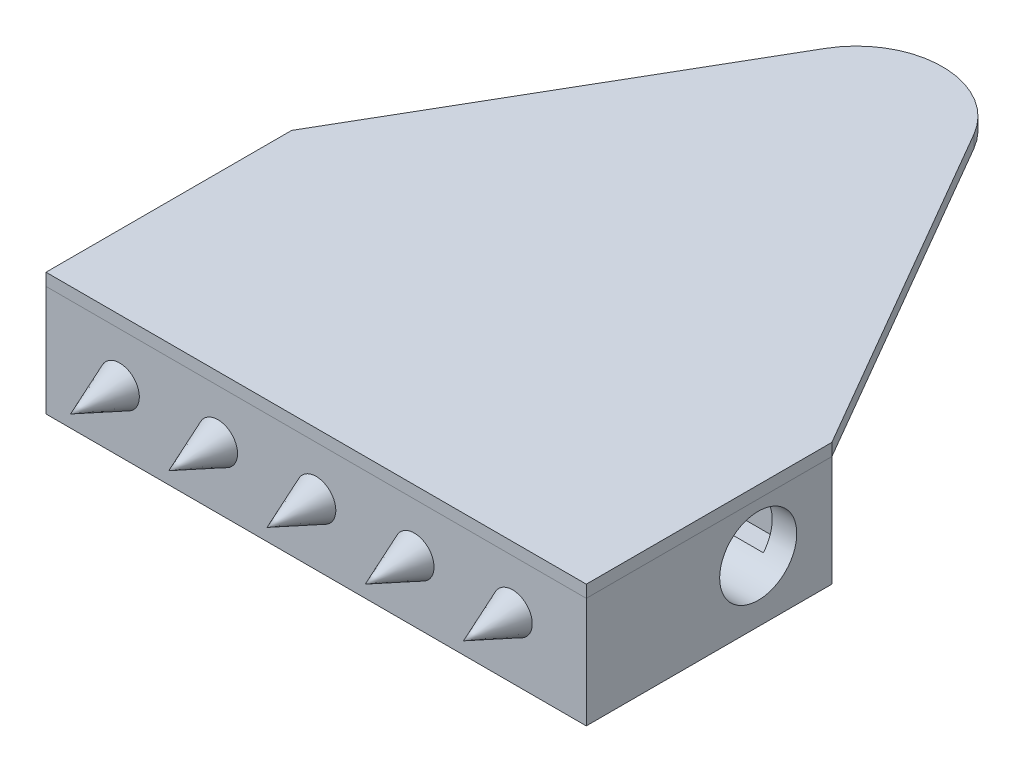
from build123d import *

# Parameters (mm, degrees)
SKETCH3_W                = 139.7
SKETCH3_H                = 63.5
SKETCH3_W_2              = 127
SKETCH3_H_2              = 50.8
BOSS_EXTRUDE1_DEPTH      = 12.7
BOSS_EXTRUDE1_DEPTH_BACK = 12.7
SKETCH4_W                = 139.7
SKETCH4_H                = 63.5
BOSS_EXTRUDE2_DEPTH      = 3.175
BOSS_EXTRUDE3_DEPTH      = 3.175
SKETCH7_W                = 44.45
SKETCH7_H                = 25.4
BOSS_EXTRUDE4_DEPTH      = 6.35
SKETCH6_R                = 9.9695
CUT_EXTRUDE1_DEPTH       = 140.7
LPATTERN1_COUNT          = 3
LPATTERN1_PITCH          = 25.4
LPATTERN1_COL_COUNT      = 3
LPATTERN1_COL_PITCH      = 25.4


with BuildPart() as part:
    # Sketch3 → Boss-Extrude1 (new body, two sides)
    with BuildSketch(Plane(origin=(0, 0, 0), x_dir=(1, 0, 0), z_dir=(0, 1, 0))) as boss_extrude1_sk:
        with Locations((0, -107.95)):
            Rectangle(SKETCH3_W, SKETCH3_H)
        with Locations((0, -107.95)):
            Rectangle(SKETCH3_W_2, SKETCH3_H_2, mode=Mode.SUBTRACT)
    extrude(amount=BOSS_EXTRUDE1_DEPTH)
    extrude(boss_extrude1_sk.sketch, amount=-BOSS_EXTRUDE1_DEPTH_BACK)

    # Sketch4 → Boss-Extrude2 (add)
    with BuildSketch(Plane.XZ.offset(12.7)):
        with Locations((0, 107.95)):
            Rectangle(SKETCH4_W, SKETCH4_H)
    extrude(amount=BOSS_EXTRUDE2_DEPTH)

    # Sketch7 → Boss-Extrude4 (add)
    with BuildSketch(Plane(origin=(0, -12.7, 0), x_dir=(1, 0, 0), z_dir=(0, 1, 0))):
        with Locations((-41.275, -95.25)):
            Rectangle(SKETCH7_W, SKETCH7_H)
        with Locations((41.275, -95.25)):
            Rectangle(SKETCH7_W, SKETCH7_H)
    extrude(amount=BOSS_EXTRUDE4_DEPTH)

    # Sketch6 → Cut-Extrude1 (cut, through all)
    with BuildSketch(Plane.ZY.offset(69.85)):
        with Locations((95.25, 0)):
            Circle(SKETCH6_R)
    extrude(amount=-CUT_EXTRUDE1_DEPTH, mode=Mode.SUBTRACT)

    # Sketch9 → Revolve1 (revolve)
    with BuildSketch(Plane(origin=(0, 0, 0), x_dir=(0, 0, -1), z_dir=(1, 0, 0))):
        Polygon((-139.7, 0), (-139.7, 5.08), (-152.4, 0), align=None)
    revolve1 = revolve(axis=Axis((0, 0, 152.4), (0, 0, -1)))

    # LPattern1: Revolve1 ×3
    with Locations(*[(-i * LPATTERN1_PITCH, 0, 0) for i in range(1, LPATTERN1_COUNT)]):
        add(revolve1)

    # LPattern1 col: Revolve1 ×3
    with Locations(*[(i * LPATTERN1_COL_PITCH, 0, 0) for i in range(1, LPATTERN1_COL_COUNT)]):
        add(revolve1)


with BuildPart() as body_2:
    # Sketch5 → Boss-Extrude3 (new body)
    with BuildSketch(Plane(origin=(0, 12.7, 0), x_dir=(1, 0, 0), z_dir=(0, 1, 0))):
        with BuildLine():
            Line((-19.229016085, 11.144306411), (-69.85, -76.2))
            Line((-69.85, -76.2), (-69.85, -139.7))
            Line((-69.85, -139.7), (69.85, -139.7))
            Line((69.85, -139.7), (69.85, -76.2))
            Line((69.85, -76.2), (19.229016085, 11.144306411))
            ThreePointArc((19.229016085, 11.144306411), (0, 22.225), (-19.229016085, 11.144306411))
        make_face()
    extrude(amount=BOSS_EXTRUDE3_DEPTH)


solid = Compound([part.part, body_2.part])
